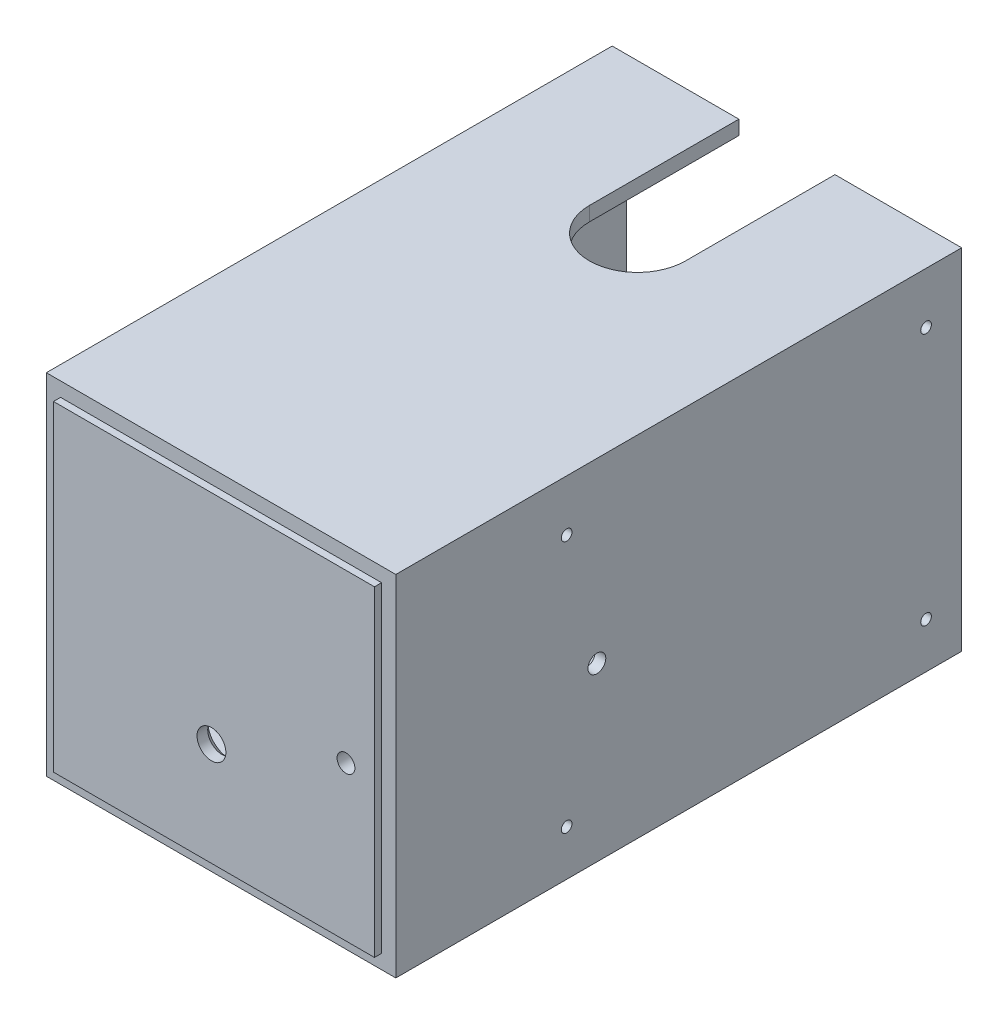
from build123d import *

# Parameters (mm, degrees)
CROQUIS1_W                   = 98.2
CROQUIS1_H                   = 98.2
SALIENTE_EXTRUIR1_DEPTH      = 160.5
SALIENTE_EXTRUIR1_DEPTH_BACK = 0.5
CROQUIS7_W                   = 91.168433898
CROQUIS7_H                   = 90.2
CORTAR_EXTRUIR3_DEPTH        = 156
PUERTAS_LATERALES_DEPTH      = 99.2
CROQUIS10_OUTSIDE_W          = 142.724
CROQUIS10_OUTSIDE_H          = 142.724
CROQUIS10_OUTSIDE_W_2        = 90.2
CROQUIS10_OUTSIDE_H_2        = 90.2
PARTE_SUP_DEPTH              = 2
REDONDEO1_R                  = 2
CROQUIS13_R                  = 4.05
CORTAR_EXTRUIR7_DEPTH        = 6
CROQUIS29_R                  = 2.5
HUECO_5V_TOP_DEPTH           = 5
CHAFL_N3_SIZE                = 2
CROQUIS34_R                  = 2.5
HUECO5V_ATRAS_DEPTH          = 4
LOGO_UIS_DEPTH               = 1
CROQUIS39_R                  = 1.5
CORTAR_EXTRUIR10_DEPTH       = 3


with BuildPart() as part:
    # Croquis1 → Saliente-Extruir1 (new body, two sides)
    with BuildSketch(Plane.XY) as saliente_extruir1_sk:
        Rectangle(CROQUIS1_W, CROQUIS1_H)
    extrude(amount=SALIENTE_EXTRUIR1_DEPTH)
    extrude(saliente_extruir1_sk.sketch, amount=-SALIENTE_EXTRUIR1_DEPTH_BACK)

    # Croquis7 → Cortar-Extruir3 (cut)
    with BuildSketch(Plane(origin=(0, 0, -0.5), x_dir=(-1, 0, 0), z_dir=(0, 0, -1))):
        with Locations((-0.514494548, 0)):
            Rectangle(CROQUIS7_W, CROQUIS7_H)
    extrude(amount=-CORTAR_EXTRUIR3_DEPTH, mode=Mode.SUBTRACT)

    # Croquis4 → puertas_laterales (cut, through all)
    with BuildSketch(Plane.XZ.offset(49.1)):
        with BuildLine():
            Line((-13.5, 41.5), (-13.5, -0.5))
            Line((-13.5, -0.5), (13.5, -0.5))
            Line((13.5, -0.5), (13.5, 41.5))
            ThreePointArc((13.5, 41.5), (0, 55), (-13.5, 41.5))
        make_face()
    extrude(amount=-PUERTAS_LATERALES_DEPTH, mode=Mode.SUBTRACT)

    # Croquis10 outside → parte_sup (cut)
    with BuildSketch(Plane.XY.offset(160.5)):
        Rectangle(CROQUIS10_OUTSIDE_W, CROQUIS10_OUTSIDE_H)
        Rectangle(CROQUIS10_OUTSIDE_W_2, CROQUIS10_OUTSIDE_H_2, mode=Mode.SUBTRACT)
    extrude(amount=-PARTE_SUP_DEPTH, mode=Mode.SUBTRACT)

    # Redondeo1
    redondeo1_edges = [part.edges().sort_by_distance(p)[0] for p in [
        (46.098711497, -45.1, 77.5),
        (46.098711497, 45.1, 77.5),
        (-45.069722401, 45.1, 77.5),
        (-45.069722401, -45.1, 77.5),
    ]]
    fillet(redondeo1_edges, radius=REDONDEO1_R)

    # Croquis13 → Cortar-Extruir7 (cut)
    with BuildSketch(Plane.XY.offset(160.5)):
        with Locations((-0.704091143, -16.1)):
            Circle(CROQUIS13_R)
    extrude(amount=-CORTAR_EXTRUIR7_DEPTH, mode=Mode.SUBTRACT)

    # Croquis29 → hueco_5v_top (cut)
    with BuildSketch(Plane.XY.offset(160.5)):
        with Locations((37.1, -1.8)):
            Circle(CROQUIS29_R)
    extrude(amount=-HUECO_5V_TOP_DEPTH, mode=Mode.SUBTRACT)

    # Chaflán3
    chafl_n3_edges = [part.edges().sort_by_distance(p)[0] for p in [
        (-4.754091143, -16.1, 155.5),
    ]]
    chamfer(chafl_n3_edges, length=CHAFL_N3_SIZE)

    # Croquis34 → hueco5v_atras (cut)
    with BuildSketch(Plane.ZY.offset(-46.098711497)):
        with Locations((102, -0.8)):
            Circle(CROQUIS34_R)
    extrude(amount=-HUECO5V_ATRAS_DEPTH, mode=Mode.SUBTRACT)

    # Croquis37 → logo_uis (cut)
    with BuildSketch(Plane.ZY.offset(49.1)):
        with BuildLine():
            Line((107.444285699, 28.673704844), (57.330814456, 28.673704844))
            ThreePointArc((57.330814456, 28.673704844), (50.001548945, 19.678649451), (45.772798952, 8.873704844))
            Line((45.772798952, 8.873704844), (119.002301204, 8.873704844))
            ThreePointArc((119.002301204, 8.873704844), (117.764010393, 13.213803539), (116.013284271, 17.373704844))
            Line((116.013284271, 17.373704844), (60.479449367, 17.373704844))
            Line((60.479449367, 17.373704844), (60.479449367, 20.173704844))
            Line((60.479449367, 20.173704844), (114.479449367, 20.173704844))
            ThreePointArc((114.479449367, 20.173704844), (111.27620041, 24.683867577), (107.444285699, 28.673704844))
        make_face()
        with BuildLine():
            Line((119.662742901, 4.873704844), (45.112357255, 4.873704844))
            ThreePointArc((45.112357255, 4.873704844), (44.887853983, 0.622732114), (45.146578017, -3.626295156))
            Line((45.146578017, -3.626295156), (119.628522138, -3.626295156))
            ThreePointArc((119.628522138, -3.626295156), (119.887246173, 0.622732114), (119.662742901, 4.873704844))
        make_face()
        with BuildLine():
            Line((76.153041157, -7.626295156), (45.84045717, -7.626295156))
            ThreePointArc((45.84045717, -7.626295156), (50.194665984, -18.458253292), (57.668933612, -27.426295156))
            Line((57.668933612, -27.426295156), (89.371002461, -27.426295156))
            Line((89.371002461, -27.426295156), (89.371002461, -16.126295156))
            Line((89.371002461, -16.126295156), (103.905626444, -16.126295156))
            Line((103.905626444, -16.126295156), (103.905626444, -18.926295156))
            Line((103.905626444, -18.926295156), (93.371002461, -18.926295156))
            Line((93.371002461, -18.926295156), (93.371002461, -27.539015822))
            Line((93.371002461, -27.539015822), (106.97697562, -27.539015822))
            ThreePointArc((106.97697562, -27.539015822), (114.536384942, -18.5317974), (118.934642985, -7.626295156))
            Line((118.934642985, -7.626295156), (81.349631319, -7.626295156))
            Line((81.349631319, -7.626295156), (81.349631319, -18.926295156))
            Line((81.349631319, -18.926295156), (58.9481168, -18.926295156))
            Line((58.9481168, -18.926295156), (58.9481168, -16.126295156))
            Line((58.9481168, -16.126295156), (76.153041157, -16.126295156))
            Line((76.153041157, -16.126295156), (76.153041157, -7.626295156))
        make_face()
    extrude(amount=-LOGO_UIS_DEPTH, mode=Mode.SUBTRACT)

    # Croquis39 → Cortar-Extruir10 (cut)
    with BuildSketch(Plane(origin=(49.1, 0, 0), x_dir=(0, 0, -1), z_dir=(1, 0, 0))):
        with Locations((-110.5, -36.3)):
            Circle(CROQUIS39_R)
        with Locations((-9.5, -36.3)):
            Circle(CROQUIS39_R)
        with Locations((-110.5, 34.7)):
            Circle(CROQUIS39_R)
        with Locations((-9.5, 34.7)):
            Circle(CROQUIS39_R)
    extrude(amount=-CORTAR_EXTRUIR10_DEPTH, mode=Mode.SUBTRACT)


solid = part.part
